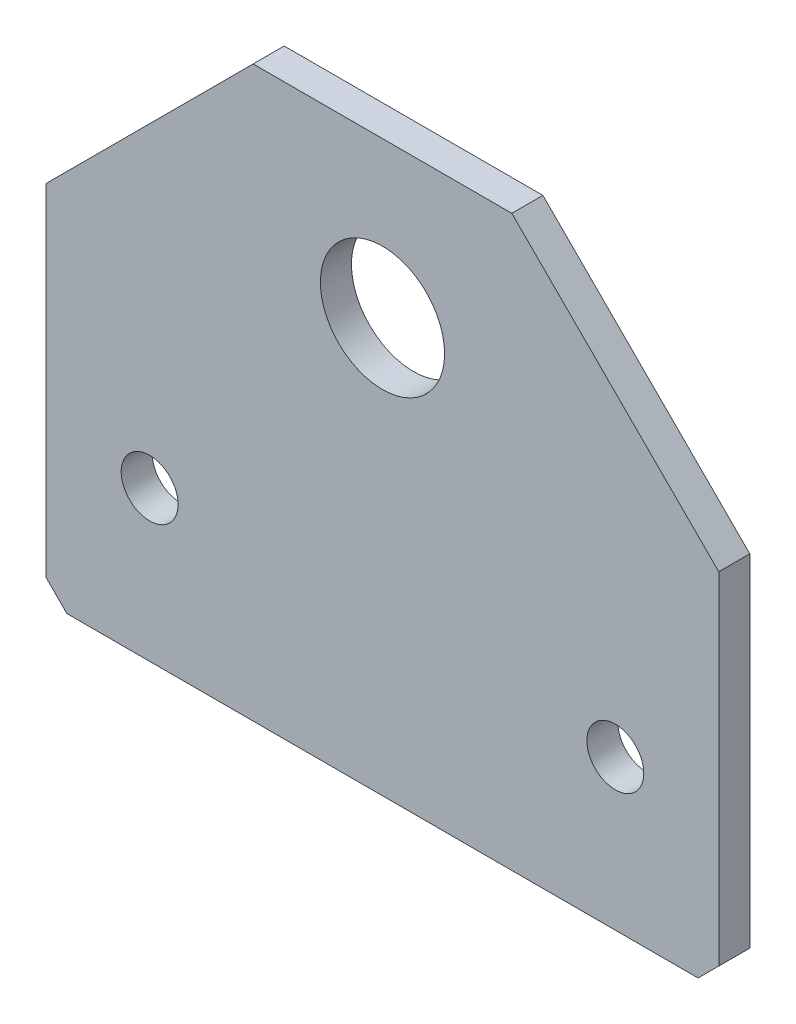
from build123d import *

# Parameters (mm, degrees)
BOSS_EXTRUDE1_DEPTH  = 3
SKETCH2_R            = 6
CUT_EXTRUDE1_DEPTH   = 4
M5_CLEARANCE_HOLE1_D = 5.5


with BuildPart() as part:
    # Sketch1 → Boss-Extrude1 (new body)
    with BuildSketch(Plane.XY):
        Polygon((-12.5, 55), (-32.5, 35), (-32.5, 2), (-30.5, 0), (30.5, 0), (32.5, 2), (32.5, 35), (12.5, 55), align=None)
    extrude(amount=BOSS_EXTRUDE1_DEPTH)

    # Sketch2 → Cut-Extrude1 (cut, through all)
    with BuildSketch(Plane.XY):
        with Locations((0, 40)):
            Circle(SKETCH2_R)
    extrude(amount=CUT_EXTRUDE1_DEPTH, mode=Mode.SUBTRACT)

    # M5 Clearance Hole1 (through all)
    with Locations(Plane.XY.offset(3)):
        with Locations((-22.5, 14.5), (22.5, 14.5)):
            Hole(M5_CLEARANCE_HOLE1_D / 2)


solid = part.part
